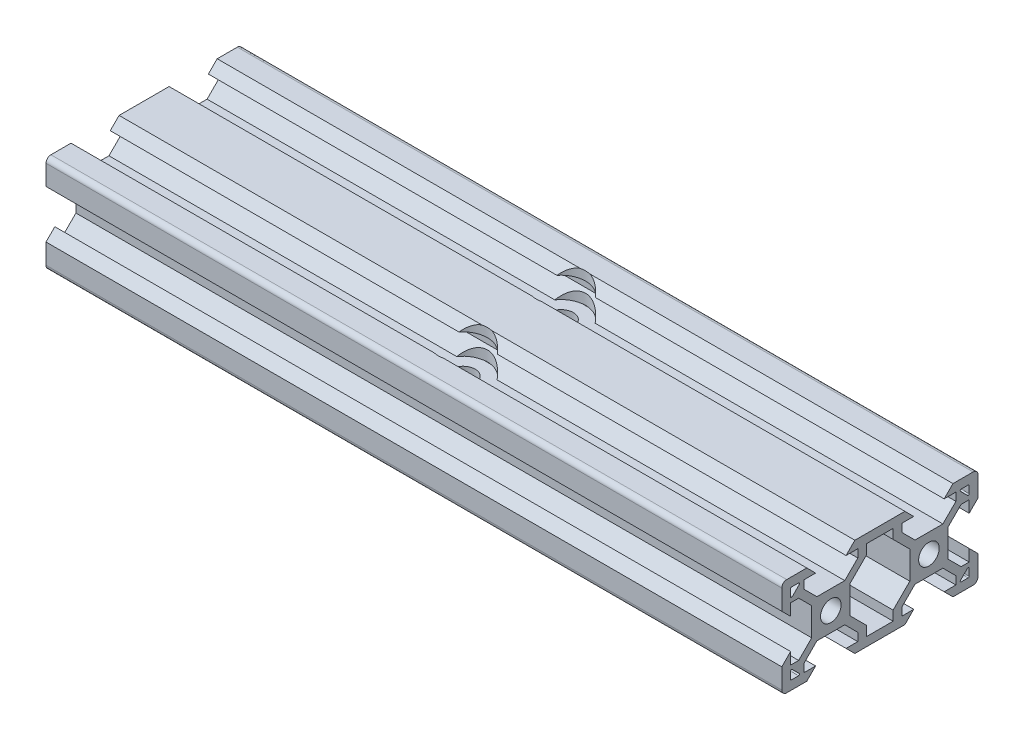
from build123d import *

# Parameters (mm, degrees)
SKETCH5_R           = 2.1
BOSS_EXTRUDE1_DEPTH = 75
CUT_EXTRUDE1_REACH  = 22
SKETCH6_R           = 2.5
SKETCH7_R           = 5
CUT_EXTRUDE2_DEPTH  = 6.1


with BuildPart() as part:
    # Sketch5 → Boss-Extrude1 (new body, symmetric)
    with BuildSketch(Plane(origin=(0, 0, 0), x_dir=(0, 0, -1), z_dir=(1, 0, 0))):
        with BuildLine():
            Line((-19.998019485, 4.9), (-18.198019485, 3.1))
            Line((-18.198019485, 3.1), (-18.198019485, 5.499339828))
            Line((-18.198019485, 5.499339828), (-16.558019485, 5.499339828))
            Line((-16.558019485, 5.499339828), (-13.9, 2.841320344))
            Line((-13.9, 2.841320344), (-13.9, -2.838679656))
            Line((-13.9, -2.838679656), (-16.558019485, -5.496699141))
            Line((-16.558019485, -5.496699141), (-18.198019485, -5.496699141))
            Line((-18.198019485, -5.496699141), (-18.198019485, -3.1))
            Line((-18.198019485, -3.1), (-19.998019485, -4.9))
            Line((-19.998019485, -4.9), (-19.998019485, -9))
            ThreePointArc((-19.998019485, -9), (-19.705126266, -9.707106781), (-18.998019485, -10))
            Line((-18.998019485, -10), (-14.9, -10))
            Line((-14.9, -10), (-13.1, -8.2))
            Line((-13.1, -8.2), (-15.5, -8.2))
            Line((-15.5, -8.2), (-15.5, -6.56))
            Line((-15.5, -6.56), (-12.84, -3.9))
            Line((-12.84, -3.9), (-7.16, -3.9))
            Line((-7.16, -3.9), (-4.5, -6.56))
            Line((-4.5, -6.56), (-4.5, -8.2))
            Line((-4.5, -8.2), (-6.9, -8.2))
            Line((-6.9, -8.2), (-5.1, -10))
            Line((-5.1, -10), (5.1, -10))
            Line((5.1, -10), (6.9, -8.2))
            Line((6.9, -8.2), (4.496038969, -8.2))
            Line((4.496038969, -8.2), (4.496038969, -6.56))
            Line((4.496038969, -6.56), (7.156038969, -3.9))
            Line((7.156038969, -3.9), (12.836038969, -3.9))
            Line((12.836038969, -3.9), (15.496038969, -6.56))
            Line((15.496038969, -6.56), (15.496038969, -8.2))
            Line((15.496038969, -8.2), (13.1, -8.2))
            Line((13.1, -8.2), (14.9, -10))
            Line((14.9, -10), (19.001980515, -10))
            ThreePointArc((19.001980515, -10), (19.709087297, -9.707106781), (20.001980515, -9))
            Line((20.001980515, -9), (20.001980515, -4.9))
            Line((20.001980515, -4.9), (18.201980515, -3.1))
            Line((18.201980515, -3.1), (18.201980515, -5.504621202))
            Line((18.201980515, -5.504621202), (16.561980515, -5.504621202))
            Line((16.561980515, -5.504621202), (13.9, -2.842640687))
            Line((13.9, -2.842640687), (13.9, 2.837359313))
            Line((13.9, 2.837359313), (16.561980515, 5.499339828))
            Line((16.561980515, 5.499339828), (18.201980515, 5.499339828))
            Line((18.201980515, 5.499339828), (18.201980515, 3.1))
            Line((18.201980515, 3.1), (20.001980515, 4.9))
            Line((20.001980515, 4.9), (20.001980515, 9))
            ThreePointArc((20.001980515, 9), (19.709087297, 9.707106781), (19.001980515, 10))
            Line((19.001980515, 10), (14.9, 10))
            Line((14.9, 10), (13.1, 8.2))
            Line((13.1, 8.2), (15.501320344, 8.2))
            Line((15.501320344, 8.2), (15.501320344, 6.56))
            Line((15.501320344, 6.56), (12.841320344, 3.9))
            Line((12.841320344, 3.9), (7.161320344, 3.9))
            Line((7.161320344, 3.9), (4.501320344, 6.56))
            Line((4.501320344, 6.56), (4.501320344, 8.2))
            Line((4.501320344, 8.2), (6.9, 8.2))
            Line((6.9, 8.2), (5.1, 10))
            Line((5.1, 10), (-5.1, 10))
            Line((-5.1, 10), (-6.9, 8.2))
            Line((-6.9, 8.2), (-4.501320344, 8.2))
            Line((-4.501320344, 8.2), (-4.501320344, 6.56))
            Line((-4.501320344, 6.56), (-7.161320344, 3.9))
            Line((-7.161320344, 3.9), (-12.841320344, 3.9))
            Line((-12.841320344, 3.9), (-15.501320344, 6.56))
            Line((-15.501320344, 6.56), (-15.501320344, 8.2))
            Line((-15.501320344, 8.2), (-13.1, 8.2))
            Line((-13.1, 8.2), (-14.9, 10))
            Line((-14.9, 10), (-18.998019485, 10))
            ThreePointArc((-18.998019485, 10), (-19.705126266, 9.707106781), (-19.998019485, 9))
            Line((-19.998019485, 9), (-19.998019485, 4.9))
        make_face()
        with Locations((-10, 0)):
            Circle(SKETCH5_R, mode=Mode.SUBTRACT)
        with Locations((10, 0)):
            Circle(SKETCH5_R, mode=Mode.SUBTRACT)
        Polygon((6.1, -2.84), (6.1, 2.84), (2.7, 6.24), (2.7, 8.2), (-2.7, 8.2), (-2.7, 6.24), (-6.1, 2.84), (-6.1, -2.84), (-2.7, -6.24), (-2.7, -8.2), (2.7, -8.2), (2.7, -6.24), align=None, mode=Mode.SUBTRACT)
        with BuildLine():
            Line((16.571320344, 8.2), (18.001980515, 8.2))
            ThreePointArc((18.001980515, 8.2), (18.143401872, 8.141421356), (18.201980515, 8))
            Line((18.201980515, 8), (18.201980515, 6.569339828))
            ThreePointArc((18.201980515, 6.569339828), (18.078517202, 6.384563922), (17.860559159, 6.427918472))
            Line((17.860559159, 6.427918472), (16.429898987, 7.858578644))
            ThreePointArc((16.429898987, 7.858578644), (16.386544437, 8.076536686), (16.571320344, 8.2))
        make_face(mode=Mode.SUBTRACT)
        with BuildLine():
            Line((16.571320344, -8.2), (18.001980515, -8.2))
            ThreePointArc((18.001980515, -8.2), (18.143401872, -8.141421356), (18.201980515, -8))
            Line((18.201980515, -8), (18.201980515, -6.569339828))
            ThreePointArc((18.201980515, -6.569339828), (18.078517202, -6.384563922), (17.860559159, -6.427918472))
            Line((17.860559159, -6.427918472), (16.429898987, -7.858578644))
            ThreePointArc((16.429898987, -7.858578644), (16.386544437, -8.076536686), (16.571320344, -8.2))
        make_face(mode=Mode.SUBTRACT)
        with BuildLine():
            Line((-17.860559159, 6.427918472), (-16.429898987, 7.858578644))
            ThreePointArc((-16.429898987, 7.858578644), (-16.386544437, 8.076536686), (-16.571320344, 8.2))
            Line((-16.571320344, 8.2), (-18.001980515, 8.2))
            ThreePointArc((-18.001980515, 8.2), (-18.143401872, 8.141421356), (-18.201980515, 8))
            Line((-18.201980515, 8), (-18.201980515, 6.569339828))
            ThreePointArc((-18.201980515, 6.569339828), (-18.078517202, 6.384563922), (-17.860559159, 6.427918472))
        make_face(mode=Mode.SUBTRACT)
        with BuildLine():
            Line((-16.571320344, -8.2), (-18.001980515, -8.2))
            ThreePointArc((-18.001980515, -8.2), (-18.143401872, -8.141421356), (-18.201980515, -8))
            Line((-18.201980515, -8), (-18.201980515, -6.569339828))
            ThreePointArc((-18.201980515, -6.569339828), (-18.078517202, -6.384563922), (-17.860559159, -6.427918472))
            Line((-17.860559159, -6.427918472), (-16.429898987, -7.858578644))
            ThreePointArc((-16.429898987, -7.858578644), (-16.386544437, -8.076536686), (-16.571320344, -8.2))
        make_face(mode=Mode.SUBTRACT)
    extrude(amount=BOSS_EXTRUDE1_DEPTH, both=True)

    # Sketch6 → Cut-Extrude1 (cut, up to next)
    with BuildSketch(Plane(origin=(0, 10, 0), x_dir=(1, 0, 0), z_dir=(0, 1, 0)), mode=Mode.PRIVATE) as cut_extrude1_sk1:
        with Locations((0, 10.001320344)):
            Circle(SKETCH6_R)
    cut_extrude1_tool1 = extrude(cut_extrude1_sk1.sketch, amount=-CUT_EXTRUDE1_REACH, mode=Mode.PRIVATE) & part.part
    add(cut_extrude1_tool1.solids().sort_by_distance((0, 10, -10.00132))[0], mode=Mode.SUBTRACT)
    # Sketch6 → Cut-Extrude1 (cut, up to next)
    with BuildSketch(Plane(origin=(0, 10, 0), x_dir=(1, 0, 0), z_dir=(0, 1, 0)), mode=Mode.PRIVATE) as cut_extrude1_sk2:
        with Locations((0, -10.001320344)):
            Circle(SKETCH6_R)
    cut_extrude1_tool2 = extrude(cut_extrude1_sk2.sketch, amount=-CUT_EXTRUDE1_REACH, mode=Mode.PRIVATE) & part.part
    add(cut_extrude1_tool2.solids().sort_by_distance((0, 10, 10.00132))[0], mode=Mode.SUBTRACT)

    # Sketch7 → Cut-Extrude2 (cut)
    with BuildSketch(Plane(origin=(0, 10, 0), x_dir=(1, 0, 0), z_dir=(0, 1, 0))):
        with Locations((0, 10.001320344)):
            Circle(SKETCH7_R)
        with Locations((0, -10.001320344)):
            Circle(SKETCH7_R)
    extrude(amount=-CUT_EXTRUDE2_DEPTH, mode=Mode.SUBTRACT)


solid = part.part
